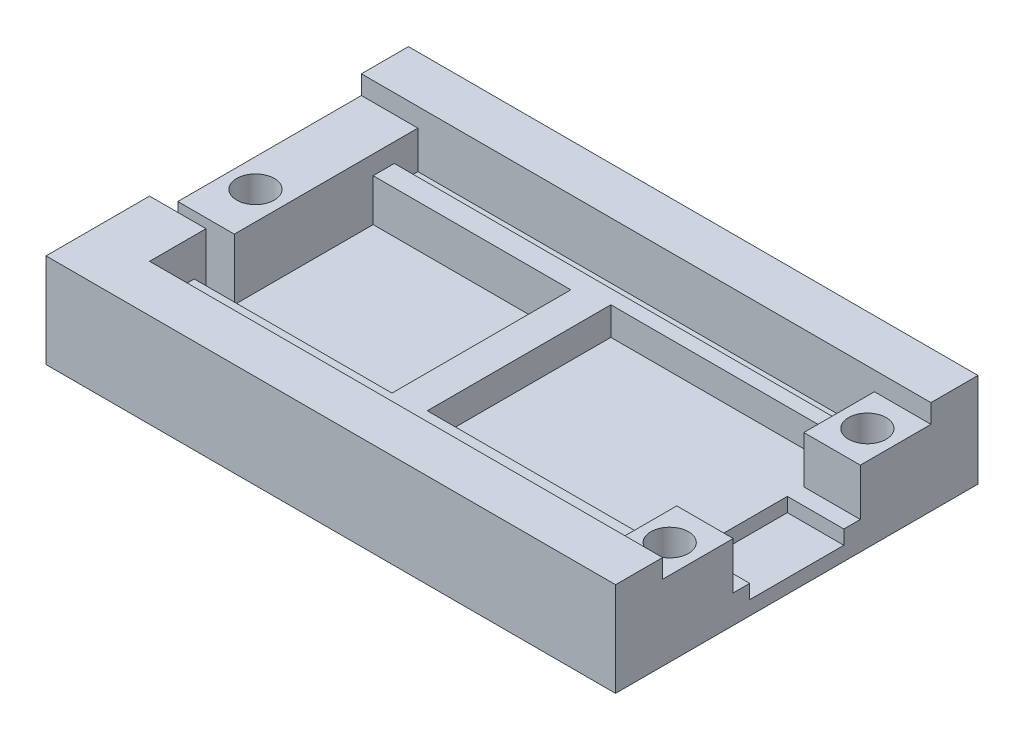
from build123d import *

# Parameters (mm, degrees)
SKETCH1_W           = 60.5
SKETCH1_H           = 38.5
BOSS_EXTRUDE1_DEPTH = 6
BOSS_EXTRUDE2_DEPTH = 4
SKETCH4_W           = 6
SKETCH4_H           = 19.5
BOSS_EXTRUDE4_DEPTH = 2
SKETCH6_R           = 2
CUT_EXTRUDE1_DEPTH  = 9
SKETCH7_W           = 48.5
SKETCH7_H           = 2.5
CUT_EXTRUDE2_DEPTH  = 2
CUT_EXTRUDE3_DEPTH  = 4.5
CUT_EXTRUDE4_DEPTH  = 3
SKETCH10_W          = 6
SKETCH10_H          = 7.5
CUT_EXTRUDE5_DEPTH  = 2
SKETCH13_W          = 6
SKETCH13_H          = 10
CUT_EXTRUDE6_DEPTH  = 1.5
CUT_EXTRUDE7_REACH  = 10
SKETCH14_R          = 2


with BuildPart() as part:
    # Sketch1 → Boss-Extrude1 (new body)
    with BuildSketch(Plane(origin=(0, 0, 0), x_dir=(1, 0, 0), z_dir=(0, 1, 0))):
        with Locations((6.235680191, -0.331443914)):
            Rectangle(SKETCH1_W, SKETCH1_H)
    extrude(amount=BOSS_EXTRUDE1_DEPTH)

    # Sketch2 → Boss-Extrude2 (add)
    with BuildSketch(Plane(origin=(0, 6, 0), x_dir=(1, 0, 0), z_dir=(0, 1, 0))):
        Polygon((-24.014319809, -19.581443914), (36.485680191, -19.581443914), (36.485680191, -14.581443914), (36.485680191, -7.081443914), (30.485680191, -7.081443914), (30.485680191, -14.581443914), (-18.014319809, -14.581443914), (-18.014319809, -8.581443914), (-24.014319809, -8.581443914), (-24.014319809, -14.581443914), align=None)
        Polygon((-24.014319809, 18.918556086), (36.485680191, 18.918556086), (36.485680191, 13.918556086), (36.485680191, 6.418556086), (30.485680191, 6.418556086), (30.485680191, 13.918556086), (-24.014319809, 13.918556086), align=None)
    extrude(amount=BOSS_EXTRUDE2_DEPTH)

    # Sketch4 → Boss-Extrude4 (add)
    with BuildSketch(Plane(origin=(0, 6, 0), x_dir=(1, 0, 0), z_dir=(0, 1, 0))):
        with Locations((-21.014319809, 4.168556086)):
            Rectangle(SKETCH4_W, SKETCH4_H)
    extrude(amount=BOSS_EXTRUDE4_DEPTH)

    # Sketch6 → Cut-Extrude1 (cut, through all)
    with BuildSketch(Plane(origin=(0, 8, 0), x_dir=(1, 0, 0), z_dir=(0, 1, 0))):
        with Locations((-21.014319809, -0.331443914)):
            Circle(SKETCH6_R)
    extrude(amount=-CUT_EXTRUDE1_DEPTH, mode=Mode.SUBTRACT)

    # Sketch7 → Cut-Extrude2 (cut)
    with BuildSketch(Plane(origin=(0, 6, 0), x_dir=(1, 0, 0), z_dir=(0, 1, 0))):
        with Locations((6.235680191, 12.668556086)):
            Rectangle(SKETCH7_W, SKETCH7_H)
        with Locations((6.235680191, -13.331443914)):
            Rectangle(SKETCH7_W, SKETCH7_H)
    extrude(amount=-CUT_EXTRUDE2_DEPTH, mode=Mode.SUBTRACT)

    # Sketch8 → Cut-Extrude3 (cut)
    with BuildSketch(Plane(origin=(0, 6, 0), x_dir=(1, 0, 0), z_dir=(0, 1, 0))):
        Polygon((-18.014319809, -5.581443914), (-18.014319809, 9.168556086), (2.985680191, 9.168556086), (2.985680191, -8.581443914), (2.985680191, -9.831443914), (-18.014319809, -9.831443914), (-18.014319809, -8.581443914), (-24.014319809, -8.581443914), (-24.014319809, -5.581443914), align=None)
    extrude(amount=-CUT_EXTRUDE3_DEPTH, mode=Mode.SUBTRACT)

    # Sketch9 → Cut-Extrude4 (cut)
    with BuildSketch(Plane(origin=(0, 6, 0), x_dir=(1, 0, 0), z_dir=(0, 1, 0))):
        Polygon((30.485680191, 9.918556086), (6.485680191, 9.918556086), (6.485680191, -9.581443914), (30.485680191, -9.581443914), (30.485680191, -7.081443914), (36.485680191, -7.081443914), (36.485680191, 6.418556086), (30.485680191, 6.418556086), align=None)
    extrude(amount=-CUT_EXTRUDE4_DEPTH, mode=Mode.SUBTRACT)

    # Sketch10 → Cut-Extrude5 (cut)
    with BuildSketch(Plane(origin=(0, 10, 0), x_dir=(1, 0, 0), z_dir=(0, 1, 0))):
        with Locations((33.485680191, 10.168556086)):
            Rectangle(SKETCH10_W, SKETCH10_H)
        with Locations((33.485680191, -10.831443914)):
            Rectangle(SKETCH10_W, SKETCH10_H)
    extrude(amount=-CUT_EXTRUDE5_DEPTH, mode=Mode.SUBTRACT)

    # Sketch13 → Cut-Extrude6 (cut)
    with BuildSketch(Plane(origin=(0, 3, 0), x_dir=(1, 0, 0), z_dir=(0, 1, 0))):
        with Locations((33.485680191, -0.331443914)):
            Rectangle(SKETCH13_W, SKETCH13_H)
    extrude(amount=-CUT_EXTRUDE6_DEPTH, mode=Mode.SUBTRACT)

    # Sketch14 → Cut-Extrude7 (cut, up to next)
    with BuildSketch(Plane(origin=(0, 8, 0), x_dir=(1, 0, 0), z_dir=(0, 1, 0)), mode=Mode.PRIVATE) as cut_extrude7_sk1:
        with Locations((33.485680191, -10.831443914)):
            Circle(SKETCH14_R)
    cut_extrude7_tool1 = extrude(cut_extrude7_sk1.sketch, amount=-CUT_EXTRUDE7_REACH, mode=Mode.PRIVATE) & part.part
    add(cut_extrude7_tool1.solids().sort_by_distance((33.48568, 8, 10.831444))[0], mode=Mode.SUBTRACT)
    # Sketch14 → Cut-Extrude7 (cut, up to next)
    with BuildSketch(Plane(origin=(0, 8, 0), x_dir=(1, 0, 0), z_dir=(0, 1, 0)), mode=Mode.PRIVATE) as cut_extrude7_sk2:
        with Locations((33.485680191, 10.168556086)):
            Circle(SKETCH14_R)
    cut_extrude7_tool2 = extrude(cut_extrude7_sk2.sketch, amount=-CUT_EXTRUDE7_REACH, mode=Mode.PRIVATE) & part.part
    add(cut_extrude7_tool2.solids().sort_by_distance((33.48568, 8, -10.168556))[0], mode=Mode.SUBTRACT)


solid = part.part
